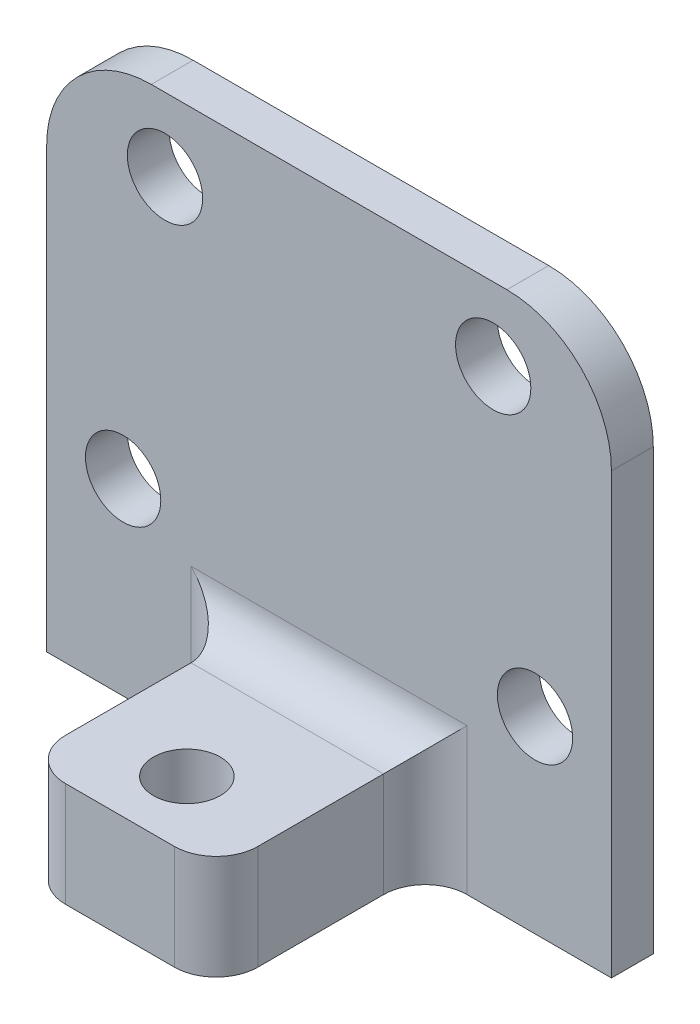
from build123d import *

# Parameters (mm, degrees)
SKETCH1_W           = 27
SKETCH1_H           = 26
BOSS_EXTRUDE1_DEPTH = 2
SKETCH2_W           = 27
SKETCH2_H           = 5
BOSS_EXTRUDE2_DEPTH = 10
CUT_EXTRUDE1_REACH  = 28
SKETCH3_R           = 1.6
SKETCH4_W           = 8.9
SKETCH4_H           = 10
CUT_EXTRUDE2_DEPTH  = 5
CUT_EXTRUDE3_REACH  = 14
SKETCH5_R           = 1.8
FILLET1_R           = 5
FILLET2_R           = 2
FILLET3_R           = 2


with BuildPart() as part:
    # Sketch1 → Boss-Extrude1 (new body)
    with BuildSketch(Plane.XY):
        with Locations((0, 13)):
            Rectangle(SKETCH1_W, SKETCH1_H)
    extrude(amount=BOSS_EXTRUDE1_DEPTH)

    # Sketch2 → Boss-Extrude2 (add)
    with BuildSketch(Plane.XY.offset(2)):
        with Locations((0, 2.5)):
            Rectangle(SKETCH2_W, SKETCH2_H)
    extrude(amount=BOSS_EXTRUDE2_DEPTH)

    # Sketch3 → Cut-Extrude1 (cut, up to next)
    with BuildSketch(Plane.XZ, mode=Mode.PRIVATE) as cut_extrude1_sk1:
        with Locations((0, 8.8)):
            Circle(SKETCH3_R)
    cut_extrude1_tool1 = extrude(cut_extrude1_sk1.sketch, amount=-CUT_EXTRUDE1_REACH, mode=Mode.PRIVATE) & part.part
    add(cut_extrude1_tool1.solids().sort_by_distance((0, 0, 8.8))[0], mode=Mode.SUBTRACT)

    # Sketch4 → Cut-Extrude2 (cut)
    with BuildSketch(Plane(origin=(0, 5, 0), x_dir=(1, 0, 0), z_dir=(0, 1, 0))):
        with Locations((9.05, -7)):
            Rectangle(SKETCH4_W, SKETCH4_H)
    cut_extrude2 = extrude(amount=-CUT_EXTRUDE2_DEPTH, mode=Mode.SUBTRACT)

    # Mirror1: Cut-Extrude2 across plane
    add(cut_extrude2.mirror(Plane(origin=(0, 0, 0), x_dir=(0, 0, 1), z_dir=(1, 0, 0))), mode=Mode.SUBTRACT)

    # Sketch5 → Cut-Extrude3 (cut, up to next)
    with BuildSketch(Plane(origin=(0, 0, 0), x_dir=(-1, 0, 0), z_dir=(0, 0, -1)), mode=Mode.PRIVATE) as cut_extrude3_sk1:
        with Locations((-7.845874534, 22.5)):
            Circle(SKETCH5_R)
    cut_extrude3_tool1 = extrude(cut_extrude3_sk1.sketch, amount=-CUT_EXTRUDE3_REACH, mode=Mode.PRIVATE) & part.part
    add(cut_extrude3_tool1.solids().sort_by_distance((7.845875, 22.5, 0))[0], mode=Mode.SUBTRACT)
    # Sketch5 → Cut-Extrude3 (cut, up to next)
    with BuildSketch(Plane(origin=(0, 0, 0), x_dir=(-1, 0, 0), z_dir=(0, 0, -1)), mode=Mode.PRIVATE) as cut_extrude3_sk2:
        with Locations((7.845874534, 22.5)):
            Circle(SKETCH5_R)
    cut_extrude3_tool2 = extrude(cut_extrude3_sk2.sketch, amount=-CUT_EXTRUDE3_REACH, mode=Mode.PRIVATE) & part.part
    add(cut_extrude3_tool2.solids().sort_by_distance((-7.845875, 22.5, 0))[0], mode=Mode.SUBTRACT)
    # Sketch5 → Cut-Extrude3 (cut, up to next)
    with BuildSketch(Plane(origin=(0, 0, 0), x_dir=(-1, 0, 0), z_dir=(0, 0, -1)), mode=Mode.PRIVATE) as cut_extrude3_sk3:
        with Locations((-9.846580197, 9)):
            Circle(SKETCH5_R)
    cut_extrude3_tool3 = extrude(cut_extrude3_sk3.sketch, amount=-CUT_EXTRUDE3_REACH, mode=Mode.PRIVATE) & part.part
    add(cut_extrude3_tool3.solids().sort_by_distance((9.84658, 9, 0))[0], mode=Mode.SUBTRACT)
    # Sketch5 → Cut-Extrude3 (cut, up to next)
    with BuildSketch(Plane(origin=(0, 0, 0), x_dir=(-1, 0, 0), z_dir=(0, 0, -1)), mode=Mode.PRIVATE) as cut_extrude3_sk4:
        with Locations((9.846580197, 9)):
            Circle(SKETCH5_R)
    cut_extrude3_tool4 = extrude(cut_extrude3_sk4.sketch, amount=-CUT_EXTRUDE3_REACH, mode=Mode.PRIVATE) & part.part
    add(cut_extrude3_tool4.solids().sort_by_distance((-9.84658, 9, 0))[0], mode=Mode.SUBTRACT)

    # Fillet1
    fillet1_edges = [part.edges().sort_by_distance(p)[0] for p in [
        (-13.5, 26, 1),
        (13.5, 26, 1),
    ]]
    fillet(fillet1_edges, radius=FILLET1_R)

    # Fillet2
    fillet2_edges = [part.edges().sort_by_distance(p)[0] for p in [
        (0, 5, 2),
        (4.6, 2.5, 2),
        (-4.6, 2.5, 2),
    ]]
    fillet(fillet2_edges, radius=FILLET2_R)

    # Fillet3
    fillet3_edges = [part.edges().sort_by_distance(p)[0] for p in [
        (4.6, 2.5, 12),
        (-4.6, 2.5, 12),
    ]]
    fillet(fillet3_edges, radius=FILLET3_R)


solid = part.part
